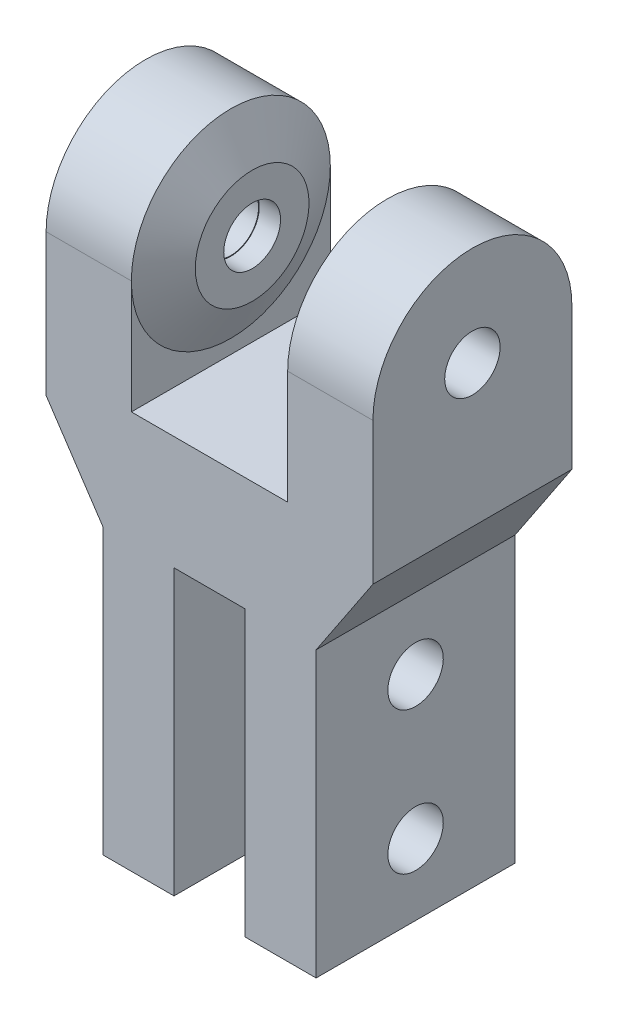
from build123d import *

# Parameters (mm, degrees)
BOSS_EXTRUDE1_DEPTH = 3.5
SKETCH2_R           = 0.975
CUT_EXTRUDE1_DEPTH  = 7.5


with BuildPart() as part:
    # Sketch1 → Boss-Extrude1 (new body, symmetric)
    with BuildSketch(Plane.XY):
        Polygon((-1.25, -10), (-3.75, -10), (-3.75, 0), (-5.75, 3), (-5.75, 12), (-4.25, 12), (-2.75, 12), (-2.75, 4), (2.75, 4), (2.75, 12), (4.25, 12), (5.75, 12), (5.75, 3), (3.75, 0), (3.75, -10), (1.25, -10), (1.25, 0), (-1.25, 0), align=None)
    extrude(amount=BOSS_EXTRUDE1_DEPTH, both=True)

    # Sketch2 → Cut-Extrude1 (cut, symmetric)
    with BuildSketch(Plane(origin=(0, 0, 0), x_dir=(0, 0, -1), z_dir=(1, 0, 0))):
        with BuildLine():
            Line((-3.5, 12), (-3.5, 7.991246091))
            ThreePointArc((-3.5, 7.991246091), (0, 11.491246091), (3.5, 7.991246091))
            Line((3.5, 7.991246091), (3.5, 12))
            Line((3.5, 12), (-3.5, 12))
        make_face()
        with Locations((0, 7.991246091)):
            Circle(SKETCH2_R)
        with Locations((0, -2.5)):
            Circle(SKETCH2_R)
        with Locations((0, -7.5)):
            Circle(SKETCH2_R)
    extrude(amount=CUT_EXTRUDE1_DEPTH, both=True, mode=Mode.SUBTRACT)

    # Sketch3 → Revolve1 (revolve)
    with BuildSketch(Plane.XY):
        Polygon((-2.75, 8.991246091), (-2, 8.991246091), (-2, 9.991246091), (-2.75, 11.491246091), align=None)
    revolve1 = revolve(axis=Axis((-5.75, 7.991246091, 0), (1, 0, 0)))

    # Mirror1: Revolve1 across plane
    add(revolve1.mirror(Plane(origin=(0, 0, 0), x_dir=(0, 0, 1), z_dir=(1, 0, 0))))


solid = part.part
